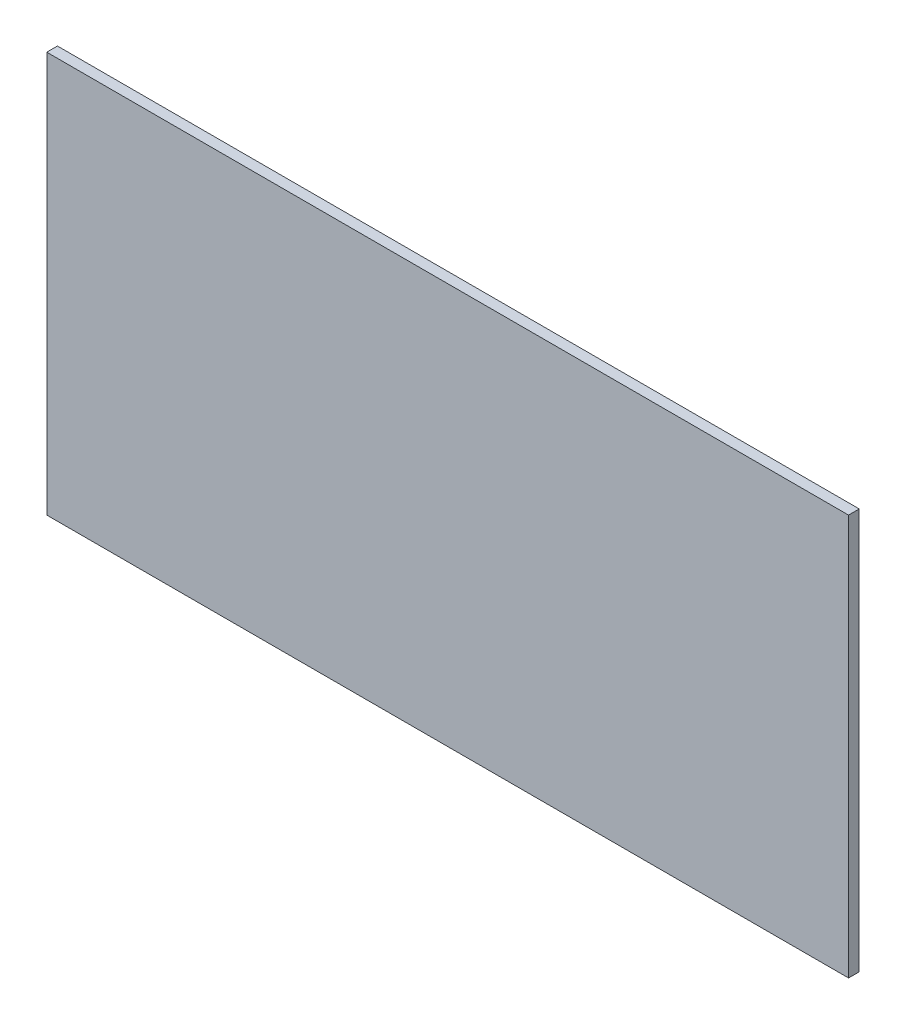
from build123d import *

# Parameters (mm, degrees)
SKETCH2_W           = 900
SKETCH2_H           = 450
BOSS_EXTRUDE1_DEPTH = 12


with BuildPart() as part:
    # Sketch2 → Boss-Extrude1 (new body)
    with BuildSketch(Plane.XY):
        Rectangle(SKETCH2_W, SKETCH2_H)
    extrude(amount=BOSS_EXTRUDE1_DEPTH)


solid = part.part
